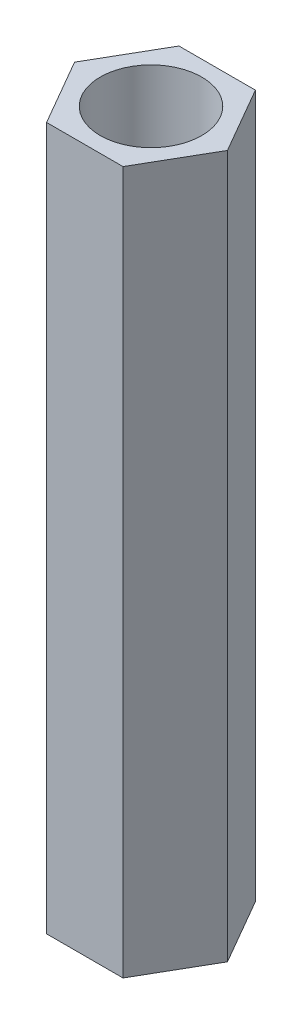
from build123d import *

# Parameters (mm, degrees)
SKETCH1_R           = 1.3
BOSS_EXTRUDE1_DEPTH = 18


with BuildPart() as part:
    # Sketch1 → Boss-Extrude1 (new body)
    with BuildSketch(Plane(origin=(0, 0, 0), x_dir=(1, 0, 0), z_dir=(0, 1, 0))):
        Polygon((0.979018569, -1.695709904), (1.958037139, 0), (0.979018569, 1.695709904), (-0.979018569, 1.695709904), (-1.958037139, 0), (-0.979018569, -1.695709904), align=None)
        Circle(SKETCH1_R, mode=Mode.SUBTRACT)
    extrude(amount=BOSS_EXTRUDE1_DEPTH)


solid = part.part
